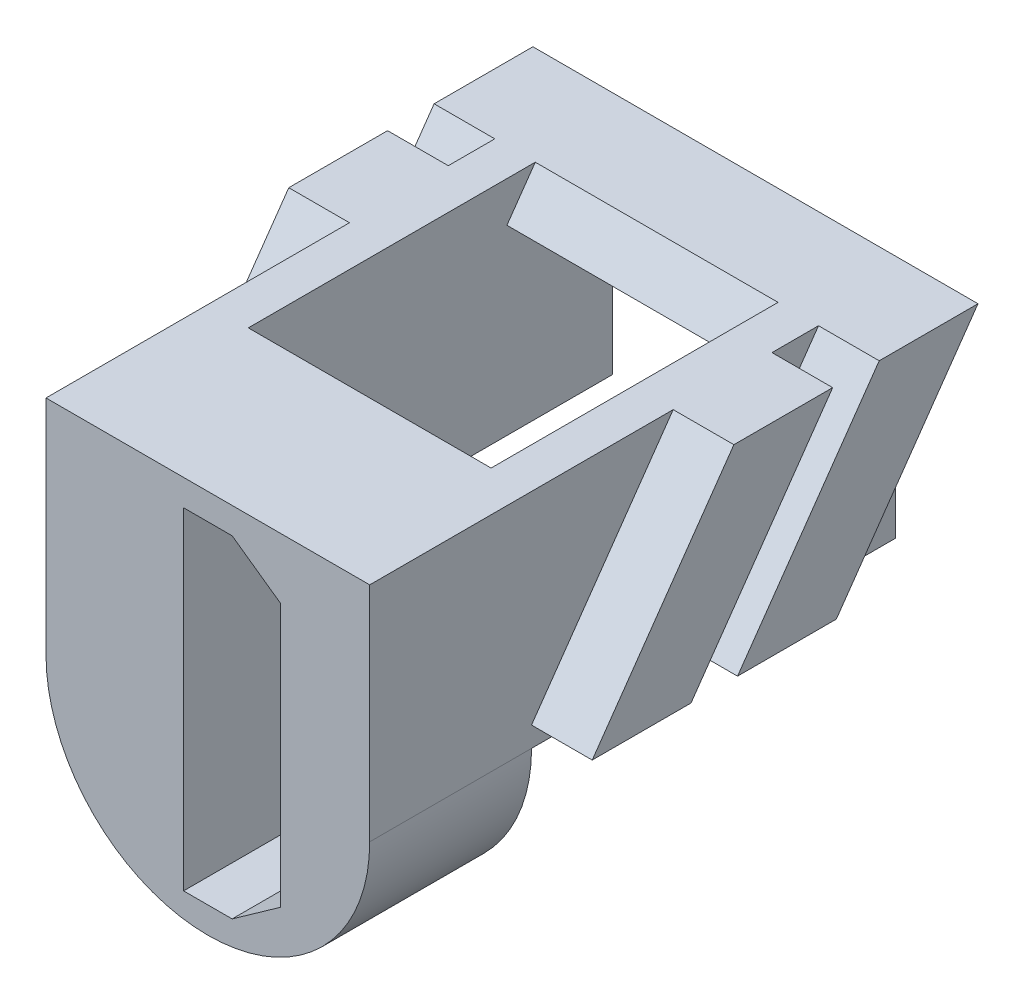
from build123d import *

# Parameters (mm, degrees)
BOSS_EXTRUDE1_DEPTH             = 6.5
BOSS_EXTRUDE2_DEPTH             = 5.5
BOSS_EXTRUDE2_DEPTH_BACK        = 5.5
CUT_EXTRUDE1_START              = -4
CUT_EXTRUDE1_DEPTH              = 25
BOSS_EXTRUDE3_REACH             = 7.5
BOSS_EXTRUDE3_DIRECTION_2_REACH = 7.5
CUT_EXTRUDE2_DEPTH              = 4


with BuildPart() as part:
    # Sketch1 → Boss-Extrude1 (new body, symmetric)
    with BuildSketch(Plane.XY):
        with BuildLine():
            Line((-4, -0.75), (-4, 4.75))
            Line((-4, 4.75), (4, 4.75))
            Line((4, 4.75), (4, -0.75))
            ThreePointArc((4, -0.75), (0, -4.75), (-4, -0.75))
        make_face()
    extrude(amount=BOSS_EXTRUDE1_DEPTH, both=True)

    # Sketch2 → Boss-Extrude2 (add, two sides)
    with BuildSketch(Plane(origin=(0, 0, 0), x_dir=(0, 0, -1), z_dir=(1, 0, 0))) as boss_extrude2_sk:
        Polygon((-2.501037691, -0.25), (-0.059488514, -0.25), (2.39940586, 3.261665098), (3.441549178, 4.75), (1, 4.75), align=None)
        Polygon((4.591549178, 4.75), (4.021496439, 3.935880318), (3.690341929, 3.462942665), (1.090511486, -0.25), (3.532060664, -0.25), (7.033098355, 4.75), align=None)
    extrude(amount=BOSS_EXTRUDE2_DEPTH)
    extrude(boss_extrude2_sk.sketch, amount=-BOSS_EXTRUDE2_DEPTH_BACK)

    # Sketch3 → Cut-Extrude1 (cut)
    with BuildSketch(Plane.XY.offset(6.5).offset(CUT_EXTRUDE1_START)):
        with BuildLine():
            Line((4, -0.75), (3, -0.75))
            Line((3, -0.75), (3, 4.75))
            Line((3, 4.75), (-3, 4.75))
            Line((-3, 4.75), (-3, -0.75))
            Line((-3, -0.75), (-4, -0.75))
            ThreePointArc((-4, -0.75), (0, -4.75), (4, -0.75))
        make_face()
    extrude(amount=-CUT_EXTRUDE1_DEPTH, mode=Mode.SUBTRACT)

    # Boss-Extrude3: up to this face of the body (flat: up to its plane)
    boss_extrude3_end = Plane(part.part.faces().sort_by_distance((5.5, 2.25, -4.061804921))[0])
    # Sketch4 → Boss-Extrude3 (add, up to the picked face)
    with BuildSketch(Plane(origin=(0, 0, 0), x_dir=(0, 0, -1), z_dir=(1, 0, 0)), mode=Mode.PRIVATE) as boss_extrude3_sk1:
        Polygon((7.033098355, 4.75), (4.591549178, 4.75), (3.891341639, 3.75), (6.332890817, 3.75), align=None)
    boss_extrude3_tool1 = split(extrude(boss_extrude3_sk1.sketch, amount=BOSS_EXTRUDE3_REACH, mode=Mode.PRIVATE), bisect_by=boss_extrude3_end, keep=Keep.BOTH, mode=Mode.PRIVATE)
    add(boss_extrude3_tool1.solids().sort_by_distance((0, 4.25, -5.46222))[0])

    # Boss-Extrude3 direction 2: up to this face of the body (flat: up to its plane)
    boss_extrude3_direction_2_end = Plane(part.part.faces().sort_by_distance((-5.5, 2.25, -4.061804921))[0])
    # Sketch4 → Boss-Extrude3 direction 2 (add, up to the picked face)
    with BuildSketch(Plane(origin=(0, 0, 0), x_dir=(0, 0, -1), z_dir=(1, 0, 0)), mode=Mode.PRIVATE) as boss_extrude3_direction_2_sk1:
        Polygon((7.033098355, 4.75), (4.591549178, 4.75), (3.891341639, 3.75), (6.332890817, 3.75), align=None)
    boss_extrude3_direction_2_tool1 = split(extrude(boss_extrude3_direction_2_sk1.sketch, amount=-BOSS_EXTRUDE3_DIRECTION_2_REACH, mode=Mode.PRIVATE), bisect_by=boss_extrude3_direction_2_end, keep=Keep.BOTH, mode=Mode.PRIVATE)
    add(boss_extrude3_direction_2_tool1.solids().sort_by_distance((0, 4.25, -5.46222))[0])

    # Sketch5 → Cut-Extrude2 (cut)
    with BuildSketch(Plane.XY.offset(6.5)):
        Polygon((-0.6, 4.1), (-0.6, -4.1), (0.6, -4.1), (1.8, -3.25), (1.8, 3.25), (0.6, 4.1), align=None)
    extrude(amount=-CUT_EXTRUDE2_DEPTH, mode=Mode.SUBTRACT)


solid = part.part
